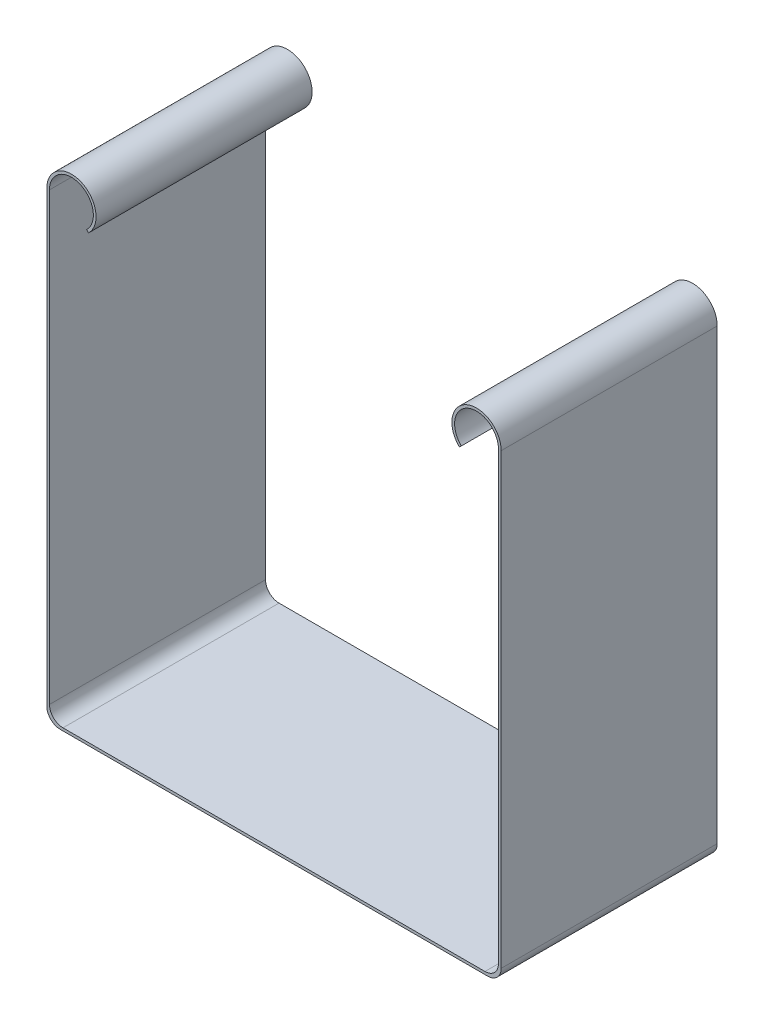
from build123d import *

# Parameters (mm, degrees)
BOSS_EXTRU_2_DEPTH = 32
CONG_2_R           = 2


with BuildPart() as part:
    # Esquisse1 → Boss.-Extru.2 (new body)
    with BuildSketch(Plane.XY):
        with BuildLine():
            Line((33.25, 68), (33.25, 34))
            Line((33.25, 34), (33.25, 0))
            Line((33.25, 0), (0, 0))
            Line((0, 0), (0, -0.4))
            Line((0, -0.4), (33.65, -0.4))
            Line((33.65, -0.4), (33.65, 34))
            Line((33.65, 34), (33.65, 68))
            ThreePointArc((33.65, 68), (28.572164781, 71.359134798), (27.46710324, 65.37189536))
            Line((27.46710324, 65.37189536), (27.75, 65.65479212))
            ThreePointArc((27.75, 65.65479212), (28.725245122, 70.989565186), (33.25, 68))
        make_face()
    extrude(amount=BOSS_EXTRU_2_DEPTH)

    # Congé2
    cong_2_edges = [part.edges().sort_by_distance(p)[0] for p in [
        (33.25, 0, 16),
        (33.65, -0.4, 16),
    ]]
    fillet(cong_2_edges, radius=CONG_2_R)

    # Symétrie2: part across plane


with BuildPart() as part_1:
    add(part.part)
    add(part.part.mirror(Plane(origin=(0, -0.4, 32), x_dir=(0, 0, 1), z_dir=(1, 0, 0))))


solid = part_1.part
